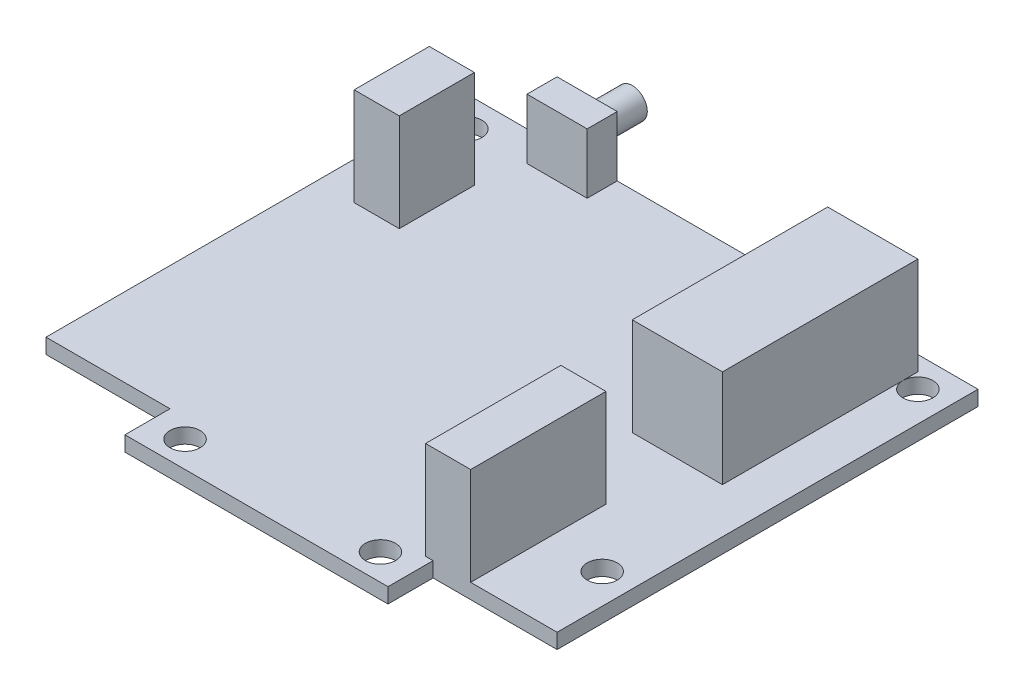
from build123d import *

# Parameters (mm, degrees)
BOSS_EXTRUDE1_DEPTH   = 1.5875
SKETCH2_W             = 4.7625
SKETCH2_H             = 7.9375
BOSS_EXTRUDE2_DEPTH   = 10.31875
SKETCH2_W_2           = 6.35
SKETCH2_H_2           = 3.175
BOSS_EXTRUDE2_2_DEPTH = 10.31875
SKETCH2_3_W           = 9.525
SKETCH2_3_H           = 20.6375
BOSS_EXTRUDE7_DEPTH   = 10.31875
BOSS_EXTRUDE8_DEPTH   = 10.31875
SKETCH3_R             = 1.5875
BOSS_EXTRUDE3_DEPTH   = 4.7625
SKETCH4_W             = 6.35
SKETCH4_H             = 3.96875
CUT_EXTRUDE1_DEPTH    = 50.2125
BOSS_EXTRUDE4_DEPTH   = 7.9375
BOSS_EXTRUDE5_DEPTH   = 6.35
SKETCH7_R             = 1.5875
CUT_EXTRUDE2_DEPTH    = 12.90625
SKETCH9_W             = 3.175
SKETCH9_H             = 2.38125
BOSS_EXTRUDE6_DEPTH   = 1.5875


with BuildPart() as part:
    # Sketch1 → Boss-Extrude1 (new body)
    with BuildSketch(Plane(origin=(0, 0, 0), x_dir=(1, 0, 0), z_dir=(0, 1, 0))):
        Polygon((13.890625, -22.225), (26.9875, -22.225), (26.9875, 22.225), (-26.9875, 22.225), (-26.9875, -22.225), (-13.890625, -22.225), (-13.890625, -26.9875), (13.890625, -26.9875), align=None)
    extrude(amount=BOSS_EXTRUDE1_DEPTH)

    # Sketch2_3 → Boss-Extrude7 (add)
    with BuildSketch(Plane(origin=(0, 1.5875, 0), x_dir=(1, 0, 0), z_dir=(0, 1, 0))):
        with Locations((17.4625, 10.31875)):
            Rectangle(SKETCH2_3_W, SKETCH2_3_H)
    extrude(amount=BOSS_EXTRUDE7_DEPTH)

    # Sketch2_4 → Boss-Extrude8 (add)
    with BuildSketch(Plane(origin=(0, 1.5875, 0), x_dir=(1, 0, 0), z_dir=(0, 1, 0))):
        Polygon((13.096875, -7.9375), (13.096875, -22.225), (13.890625, -22.225), (17.859375, -22.225), (17.859375, -7.9375), align=None)
    extrude(amount=BOSS_EXTRUDE8_DEPTH)

    # Sketch5 → Boss-Extrude4 (add)
    with BuildSketch(Plane.XZ):
        with BuildLine():
            Line((8.73125, -20.6375), (-8.73125, -20.6375))
            Line((-8.73125, -20.6375), (-8.73125, -13.890625))
            Line((-8.73125, -13.890625), (-10.31875, -13.890625))
            ThreePointArc((-10.31875, -13.890625), (-12.303125, -11.90625), (-10.31875, -9.921875))
            Line((-10.31875, -9.921875), (-8.73125, -9.921875))
            Line((-8.73125, -9.921875), (-8.73125, -3.175))
            Line((-8.73125, -3.175), (8.73125, -3.175))
            Line((8.73125, -3.175), (8.73125, -9.921875))
            Line((8.73125, -9.921875), (10.31875, -9.921875))
            ThreePointArc((10.31875, -9.921875), (12.303125, -11.90625), (10.31875, -13.890625))
            Line((10.31875, -13.890625), (8.73125, -13.890625))
            Line((8.73125, -13.890625), (8.73125, -20.6375))
        make_face()
    extrude(amount=BOSS_EXTRUDE4_DEPTH)

    # Sketch6 → Boss-Extrude5 (add)
    with BuildSketch(Plane.XZ.offset(7.9375)):
        with BuildLine():
            Line((1.190625, -20.6375), (-1.190625, -20.6375))
            Line((-1.190625, -20.6375), (-1.190625, -19.753945099))
            ThreePointArc((-1.190625, -19.753945099), (0, -3.96875), (1.190625, -19.753945099))
            Line((1.190625, -19.753945099), (1.190625, -20.6375))
        make_face()
    extrude(amount=BOSS_EXTRUDE5_DEPTH)

    # Sketch7 → Cut-Extrude2 (cut, through all)
    with BuildSketch(Plane.XZ):
        with Locations((23.8125, -19.05)):
            Circle(SKETCH7_R)
        with Locations((-23.8125, -19.05)):
            Circle(SKETCH7_R)
        with Locations((-10.31875, 24.209375)):
            Circle(SKETCH7_R)
        with Locations((10.31875, 24.209375)):
            Circle(SKETCH7_R)
        with Locations((23.8125, 14.2875)):
            Circle(SKETCH7_R)
    extrude(amount=-CUT_EXTRUDE2_DEPTH, mode=Mode.SUBTRACT)

    # Sketch9 → Boss-Extrude6 (add)
    with BuildSketch(Plane.XZ):
        with Locations((0, 23.415625)):
            Rectangle(SKETCH9_W, SKETCH9_H)
    extrude(amount=BOSS_EXTRUDE6_DEPTH)


with BuildPart() as body_2:
    # Sketch2 → Boss-Extrude2 (new body)
    with BuildSketch(Plane(origin=(0, 1.5875, 0), x_dir=(1, 0, 0), z_dir=(0, 1, 0))):
        with Locations((-20.6375, 10.31875)):
            Rectangle(SKETCH2_W, SKETCH2_H)
    extrude(amount=BOSS_EXTRUDE2_DEPTH)


with BuildPart() as body_3:
    # Sketch2 → Boss-Extrude2 2 (new body)
    with BuildSketch(Plane(origin=(0, 1.5875, 0), x_dir=(1, 0, 0), z_dir=(0, 1, 0))):
        with Locations((-14.2875, 20.6375)):
            Rectangle(SKETCH2_W_2, SKETCH2_H_2)
    extrude(amount=BOSS_EXTRUDE2_2_DEPTH)

    # Sketch4 → Cut-Extrude1 (cut, through all)
    with BuildSketch(Plane(origin=(0, 0, -22.225), x_dir=(-1, 0, 0), z_dir=(0, 0, -1))):
        with Locations((14.2875, 9.921875)):
            Rectangle(SKETCH4_W, SKETCH4_H)
    extrude(amount=-CUT_EXTRUDE1_DEPTH, mode=Mode.SUBTRACT)


with BuildPart() as body_4:
    # Sketch3 → Boss-Extrude3 (new body)
    with BuildSketch(Plane(origin=(0, 0, -22.225), x_dir=(-1, 0, 0), z_dir=(0, 0, -1))):
        with Locations((14.2875, 4.7625)):
            Circle(SKETCH3_R)
    extrude(amount=BOSS_EXTRUDE3_DEPTH)


solid = Compound([part.part, body_2.part, body_3.part, body_4.part])
